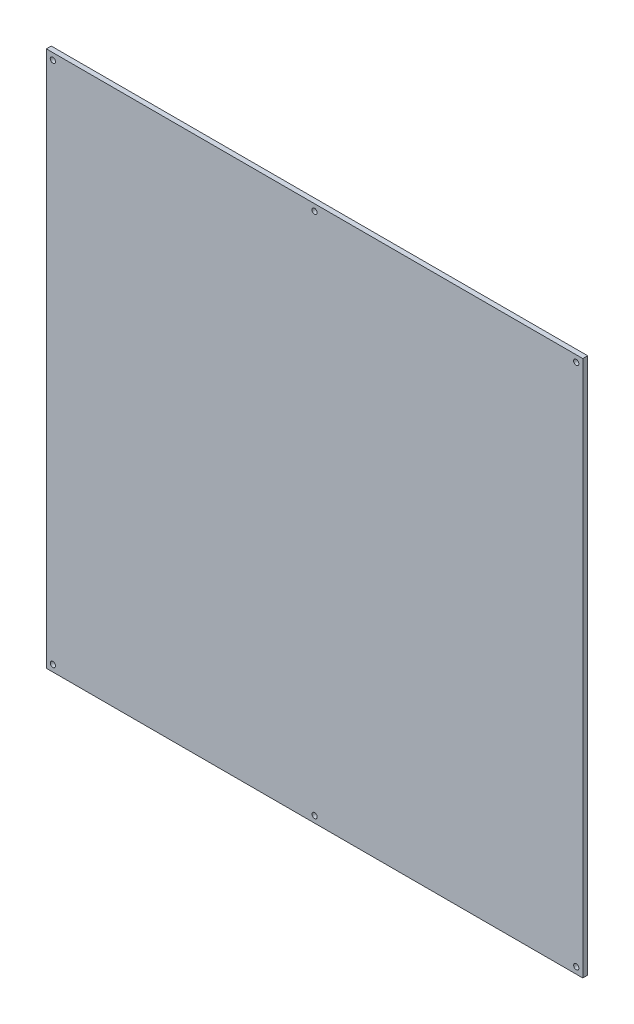
from build123d import *

# Parameters (mm, degrees)
CROQUIS1_W              = 328
CROQUIS1_H              = 328
SALIENTE_EXTRUIR1_DEPTH = 3
CROQUIS2_R              = 1.6
CORTAR_EXTRUIR1_DEPTH   = 3


with BuildPart() as part:
    # Croquis1 → Saliente-Extruir1 (new body)
    with BuildSketch(Plane.XY):
        with Locations((164, 164)):
            Rectangle(CROQUIS1_W, CROQUIS1_H)
    extrude(amount=SALIENTE_EXTRUIR1_DEPTH)

    # Croquis2 → Cortar-Extruir1 (cut)
    with BuildSketch(Plane.XY.offset(3)):
        with Locations((4, 324)):
            Circle(CROQUIS2_R)
        with Locations((164, 324)):
            Circle(CROQUIS2_R)
        with Locations((324, 324)):
            Circle(CROQUIS2_R)
        with Locations((324, 4)):
            Circle(CROQUIS2_R)
        with Locations((164, 4)):
            Circle(CROQUIS2_R)
        with Locations((4, 4)):
            Circle(CROQUIS2_R)
    extrude(amount=-CORTAR_EXTRUIR1_DEPTH, mode=Mode.SUBTRACT)


solid = part.part
